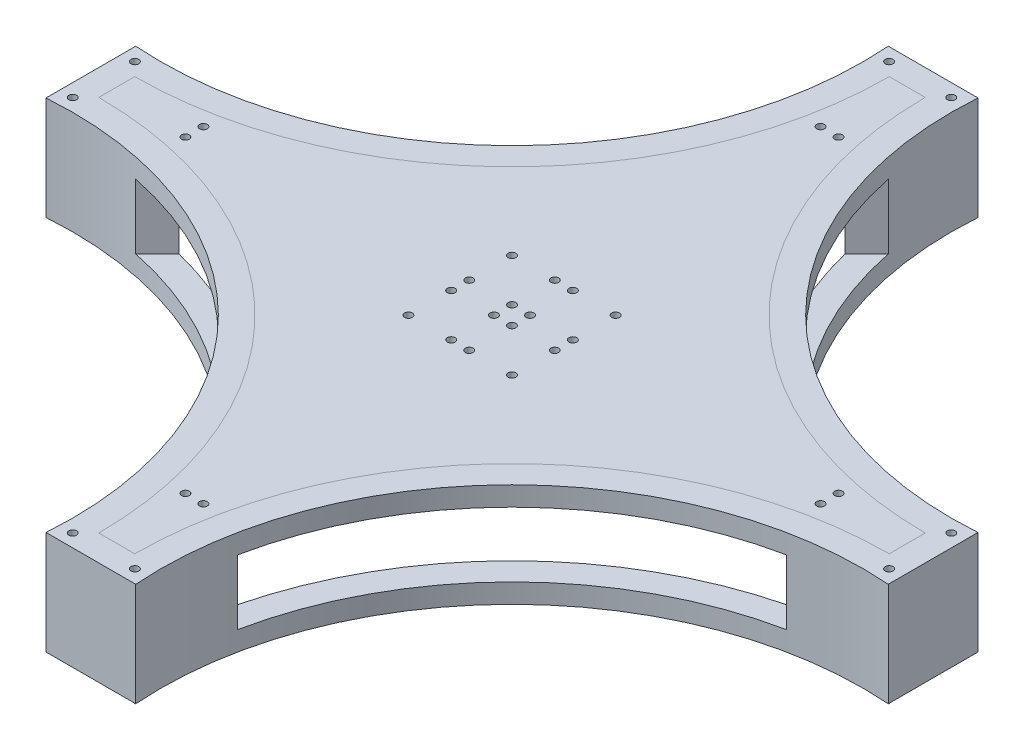
from build123d import *

# Parameters (mm, degrees)
BOSS_EXTRUDE1_DEPTH = 4
SKETCH3_R           = 1.5
CUT_EXTRUDE1_DEPTH  = 100
SKETCH4_R           = 1.5
CUT_EXTRUDE2_DEPTH  = 100
CIRPATTERN1_COUNT   = 4
BOSS_EXTRUDE2_DEPTH = 40
SKETCH8_R           = 1.5
CUT_EXTRUDE3_DEPTH  = 40
SKETCH9_W           = 150
SKETCH9_H           = 25
CUT_EXTRUDE7_DEPTH  = 59
CIRPATTERN2_COUNT   = 4


with BuildPart() as part:
    # Sketch1 → Boss-Extrude1 (new body)
    with BuildSketch(Plane(origin=(0, 0, 0), x_dir=(1, 0, 0), z_dir=(0, 1, 0))):
        with BuildLine():
            Line((-6.96, 152.66), (6.96, 152.66))
            ThreePointArc((6.96, 152.66), (49.634541981, 49.634541981), (152.66, 6.96))
            Line((152.66, 6.96), (152.66, -6.96))
            ThreePointArc((152.66, -6.96), (49.634541981, -49.634541981), (6.96, -152.66))
            Line((6.96, -152.66), (-6.96, -152.66))
            ThreePointArc((-6.96, -152.66), (-49.634541981, -49.634541981), (-152.66, -6.96))
            Line((-152.66, -6.96), (-152.66, 6.96))
            ThreePointArc((-152.66, 6.96), (-49.634541981, 49.634541981), (-6.96, 152.66))
        make_face()
    extrude(amount=BOSS_EXTRUDE1_DEPTH)

    # Sketch3 → Cut-Extrude1 (cut)
    with BuildSketch(Plane.XZ):
        with Locations((-19.995645942, -3.486531087)):
            Circle(SKETCH3_R)
        with Locations((-3.477822971, -3.486531087)):
            Circle(SKETCH3_R)
        with Locations((-3.477822971, -20.006531087)):
            Circle(SKETCH3_R)
        with Locations((-19.995645942, -20.006531087)):
            Circle(SKETCH3_R)
        with Locations((-122.66, -3.486531087)):
            Circle(SKETCH3_R)
    cut_extrude1 = extrude(amount=-CUT_EXTRUDE1_DEPTH, mode=Mode.SUBTRACT)

    # Sketch4 → Cut-Extrude2 (cut)
    with BuildSketch(Plane.XZ):
        with Locations((-3.477822971, -122.668708116)):
            Circle(SKETCH4_R)
    cut_extrude2 = extrude(amount=-CUT_EXTRUDE2_DEPTH, mode=Mode.SUBTRACT)

    # CirPattern1: Cut-Extrude1, Cut-Extrude2 ×4 about axis
    cirpattern1_axis = Axis((0, 0, 0), (0, 1, 0))
    for i in range(1, CIRPATTERN1_COUNT):
        add(cut_extrude1.rotate(cirpattern1_axis, i * 360 / CIRPATTERN1_COUNT), mode=Mode.SUBTRACT)
        add(cut_extrude2.rotate(cirpattern1_axis, i * 360 / CIRPATTERN1_COUNT), mode=Mode.SUBTRACT)


with BuildPart() as body_2:
    # Sketch6 → Boss-Extrude2 (new body)
    with BuildSketch(Plane(origin=(0, 4, 0), x_dir=(1, 0, 0), z_dir=(0, 1, 0))):
        with BuildLine():
            Line((17.328961432, 162.66), (-17.328961432, 162.66))
            ThreePointArc((-17.328961432, 162.66), (-56.705609793, 56.705609793), (-162.66, 17.328961432))
            Line((-162.66, 17.328961432), (-162.66, -17.328961432))
            ThreePointArc((-162.66, -17.328961432), (-56.705609793, -56.705609793), (-17.328961432, -162.66))
            Line((-17.328961432, -162.66), (17.328961432, -162.66))
            ThreePointArc((17.328961432, -162.66), (56.705609793, -56.705609793), (162.66, -17.328961432))
            Line((162.66, -17.328961432), (162.66, 17.328961432))
            ThreePointArc((162.66, 17.328961432), (56.705609793, 56.705609793), (17.328961432, 162.66))
        make_face()
        with BuildLine():
            Line((6.96, 152.66), (-6.96, 152.66))
            ThreePointArc((-6.96, 152.66), (-49.634541981, 49.634541981), (-152.66, 6.96))
            Line((-152.66, 6.96), (-152.66, -6.96))
            ThreePointArc((-152.66, -6.96), (-49.634541981, -49.634541981), (-6.96, -152.66))
            Line((-6.96, -152.66), (6.96, -152.66))
            ThreePointArc((6.96, -152.66), (49.634541981, -49.634541981), (152.66, -6.96))
            Line((152.66, -6.96), (152.66, 6.96))
            ThreePointArc((152.66, 6.96), (49.634541981, 49.634541981), (6.96, 152.66))
        make_face(mode=Mode.SUBTRACT)
    extrude(amount=-BOSS_EXTRUDE2_DEPTH)

    # Sketch8 → Cut-Extrude3 (cut)
    with BuildSketch(Plane.XZ.offset(36)):
        with Locations((-157.66, 12)):
            Circle(SKETCH8_R)
        with Locations((-157.66, -12)):
            Circle(SKETCH8_R)
        with Locations((-12, 157.66)):
            Circle(SKETCH8_R)
        with Locations((12, 157.66)):
            Circle(SKETCH8_R)
        with Locations((157.66, -12)):
            Circle(SKETCH8_R)
        with Locations((157.66, 12)):
            Circle(SKETCH8_R)
        with Locations((-12, -157.66)):
            Circle(SKETCH8_R)
        with Locations((12, -157.66)):
            Circle(SKETCH8_R)
    extrude(amount=-CUT_EXTRUDE3_DEPTH, mode=Mode.SUBTRACT)

    # Sketch9 → Cut-Extrude7 (cut)
    with BuildSketch(Plane(origin=(89.994480716, 0, -89.994480716), x_dir=(0.707106781, 0, 0.707106781), z_dir=(-0.707106781, 0, 0.707106781))):
        with Locations((0, -16)):
            Rectangle(SKETCH9_W, SKETCH9_H)
    cut_extrude7 = extrude(amount=CUT_EXTRUDE7_DEPTH, mode=Mode.SUBTRACT)

    # CirPattern2: Cut-Extrude7 ×4 about axis
    cirpattern2_axis = Axis((0, 0, 0), (0, 1, 0))
    for i in range(1, CIRPATTERN2_COUNT):
        add(cut_extrude7.rotate(cirpattern2_axis, i * 360 / CIRPATTERN2_COUNT), mode=Mode.SUBTRACT)


solid = Compound([part.part, body_2.part])
